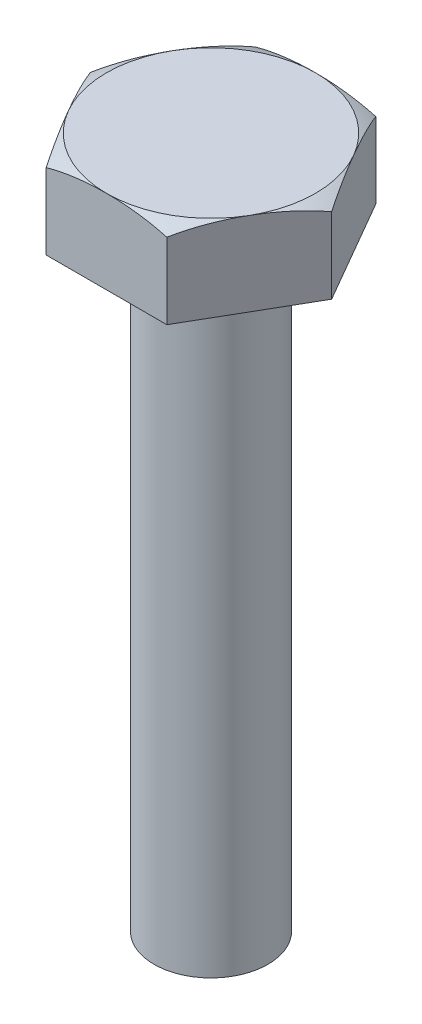
from build123d import *

# Parameters (mm, degrees)
EXTRUDE_1_DEPTH = 2.2
SKETCH_3_R      = 1.5
EXTRUDE_2_DEPTH = 16


with BuildPart() as part:
    # 草图1 → 凸台-拉伸1 (new body)
    with BuildSketch(Plane(origin=(0, 0, 0), x_dir=(1, 0, 0), z_dir=(0, 1, 0))):
        Polygon((3.175426481, 0), (1.58771324, 2.75), (-1.58771324, 2.75), (-3.175426481, 0), (-1.58771324, -2.75), (1.58771324, -2.75), align=None)
    extrude(amount=EXTRUDE_1_DEPTH)

    # 草图2 → 切除-旋转1 (revolve, cut)
    with BuildSketch(Plane(origin=(0, 0, 0), x_dir=(0, 0, -1), z_dir=(1, 0, 0))):
        with BuildLine():
            Line((-2.75, 2.2), (-4.95, 2.2))
            Line((-4.95, 2.2), (-4.95, 0))
            ThreePointArc((-4.95, 0), (-4.068803604, 1.318803604), (-2.75, 2.2))
        make_face()
    revolve(axis=Axis((0, 0, 0), (0, 1, 0)), mode=Mode.SUBTRACT)

    # 草图3 → 凸台-拉伸2 (add)
    with BuildSketch(Plane.XZ):
        Circle(SKETCH_3_R)
    extrude(amount=EXTRUDE_2_DEPTH)


solid = part.part
